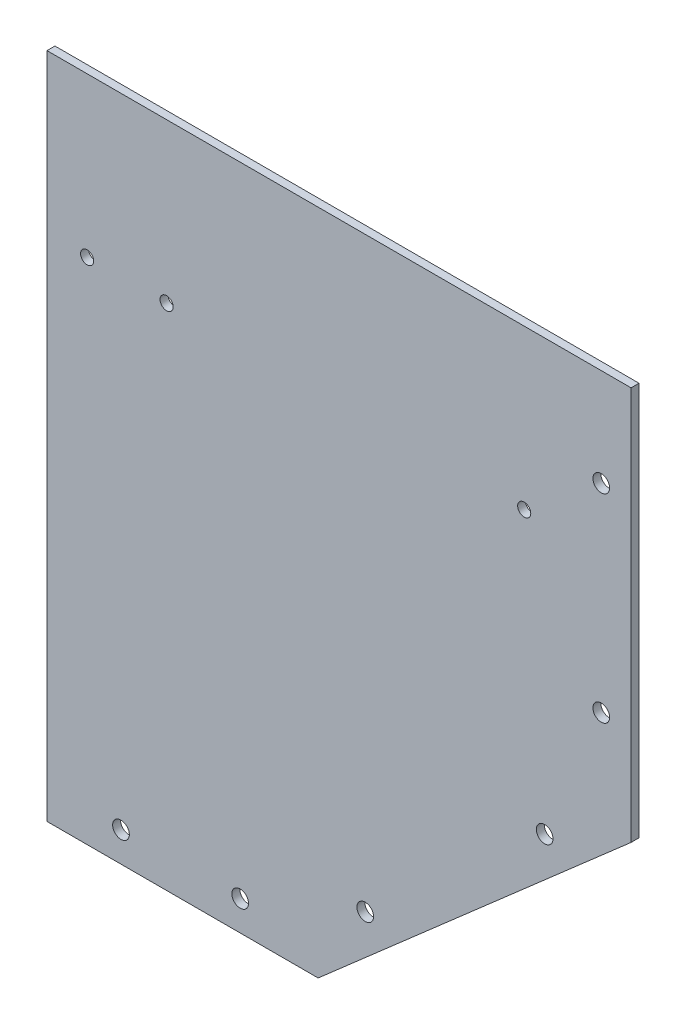
from build123d import *

# Parameters (mm, degrees)
SKETCH_1_R          = 2.1
EXTRUDE_1_DEPTH     = 2
SKETCH_3_R          = 1
CUT_EXTRUDE_1_DEPTH = 10
M4X0_7_1_D          = 3.3
M4X0_7_1_DEPTH      = 11.5
M4X0_7_1_TIP        = 0.991420021


with BuildPart() as part:
    # ｽｹｯﾁ1 → ﾎﾞｽ - 押し出し1 (new body)
    with BuildSketch(Plane.XY):
        Polygon((0, 0), (68.24, 0), (146.992249894, 68.918108191), (146.992249894, 168.01), (0, 168.01), align=None)
        with Locations((18.62, 7.5)):
            Circle(SKETCH_1_R, mode=Mode.SUBTRACT)
        with Locations((48.62, 7.5)):
            Circle(SKETCH_1_R, mode=Mode.SUBTRACT)
        with Locations((139.492249894, 93.468108191)):
            Circle(SKETCH_1_R, mode=Mode.SUBTRACT)
        with Locations((139.492249894, 143.468108191)):
            Circle(SKETCH_1_R, mode=Mode.SUBTRACT)
        with Locations((125.249072144, 59.856479125)):
            Circle(SKETCH_1_R, mode=Mode.SUBTRACT)
        with Locations((80.097280518, 20.342991391)):
            Circle(SKETCH_1_R, mode=Mode.SUBTRACT)
    extrude(amount=EXTRUDE_1_DEPTH)

    # ｽｹｯﾁ3 → ｶｯﾄ - 押し出し1 (cut)
    with BuildSketch(Plane.XY.offset(2)):
        with Locations((10.1, 128.01)):
            Circle(SKETCH_3_R)
        with Locations((30.1, 128.01)):
            Circle(SKETCH_3_R)
        with Locations((120.1, 128.01)):
            Circle(SKETCH_3_R)
    extrude(amount=-CUT_EXTRUDE_1_DEPTH, mode=Mode.SUBTRACT)

    # M4x0.7 ねじ穴1
    with Locations(Plane(origin=(10.1, 128.01, 2), x_dir=(1, 0, 0), z_dir=(0, 0, 1))):
        with Locations((0, 0), (20, 0), (110, 0)):
            Hole(M4X0_7_1_D / 2, depth=M4X0_7_1_DEPTH)
            with Locations((0, 0, -(M4X0_7_1_DEPTH + M4X0_7_1_TIP / 2))):  # 118° drill point
                Cone(0, M4X0_7_1_D / 2, M4X0_7_1_TIP, mode=Mode.SUBTRACT)


solid = part.part
